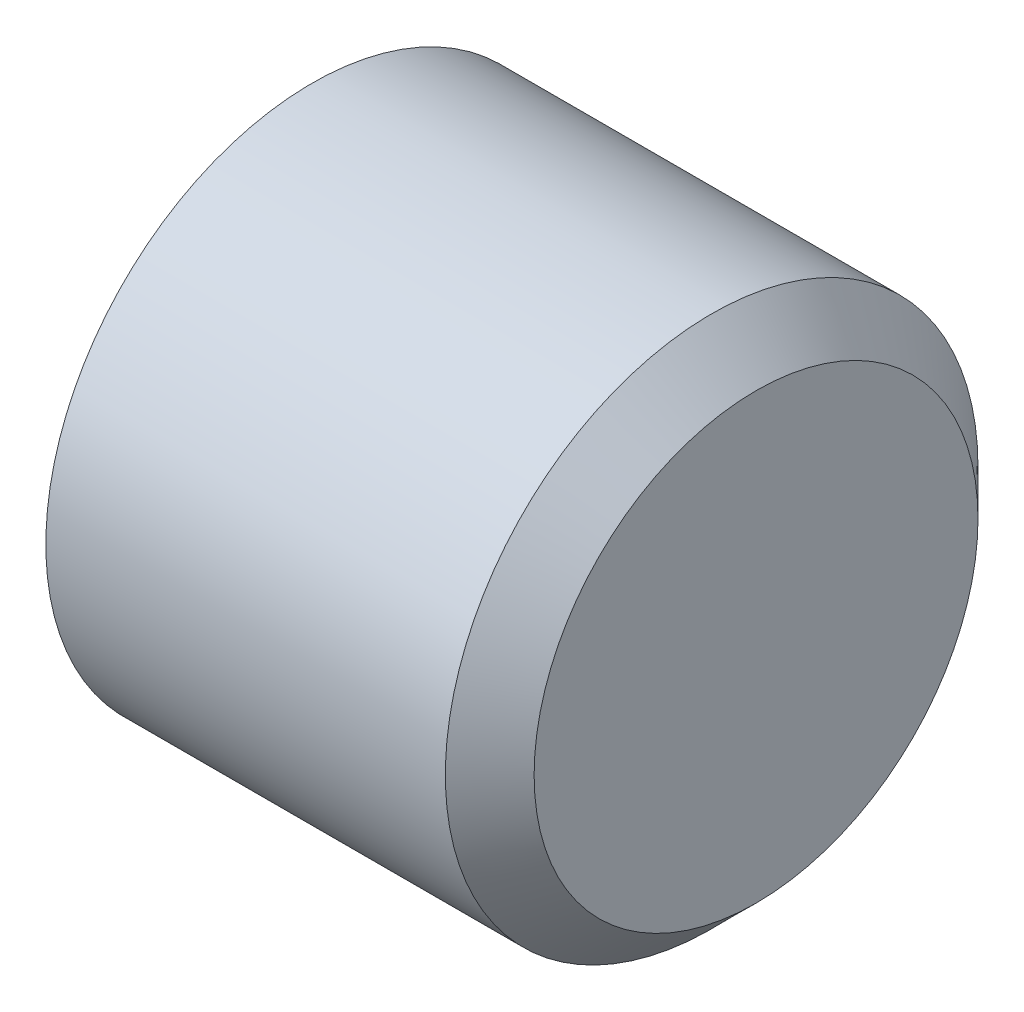
from build123d import *

# Parameters (mm, degrees)
SKETCH1_R           = 6
BOSS_EXTRUDE2_DEPTH = 5
CHAMFER1_SIZE       = 1


with BuildPart() as part:
    # Sketch1 → Boss-Extrude2 (new body, symmetric)
    with BuildSketch(Plane(origin=(0, 0, 0), x_dir=(0, 0, -1), z_dir=(1, 0, 0))):
        Circle(SKETCH1_R)
    extrude(amount=BOSS_EXTRUDE2_DEPTH, both=True)

    # Sketch5 → M6x1.0 Tapped Hole1 (revolve, cut)
    with BuildSketch(Plane(origin=(-5, 0, 0), x_dir=(0, 0, 1), z_dir=(0, 1, 0))):
        Polygon((0, 0), (0, 7.502151548), (2.5, 6), (2.5, 0), align=None)
    revolve(axis=Axis((-11.35, 0, 0), (1, 0, 0)), mode=Mode.SUBTRACT)

    # Chamfer1
    chamfer1_edges = [part.edges().sort_by_distance(p)[0] for p in [
        (5, 0, 6),
    ]]
    chamfer(chamfer1_edges, length=CHAMFER1_SIZE)


solid = part.part
